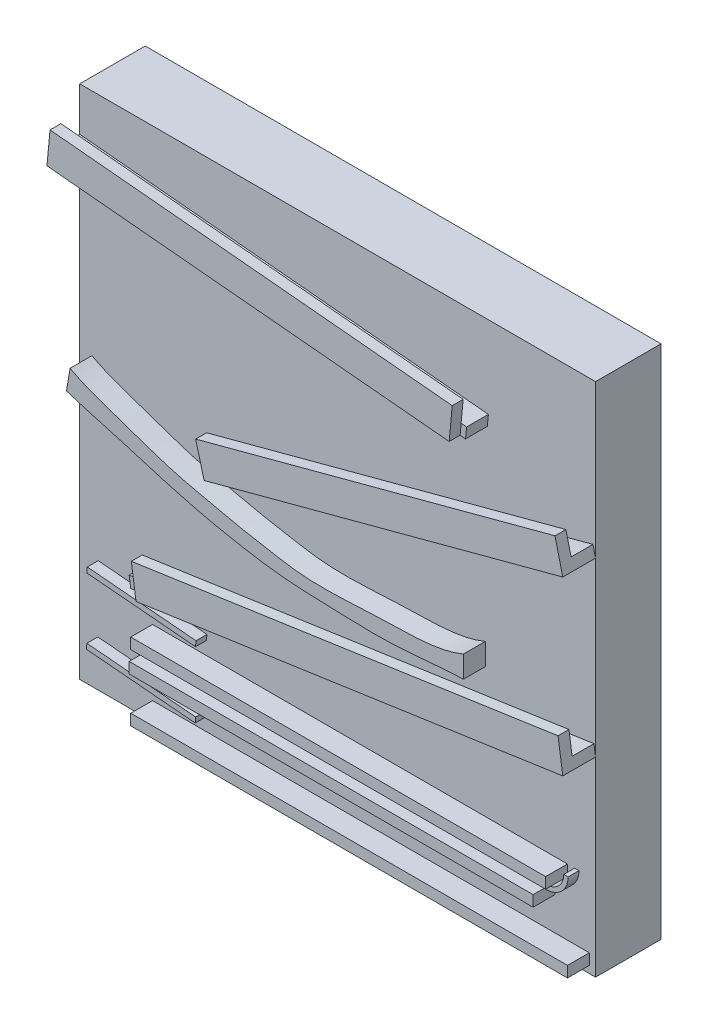
from build123d import *

# Parameters (mm, degrees)
SKETCH1_W            = 600
SKETCH1_H            = 600
BOSS_EXTRUDE1_DEPTH  = 76.2
BOSS_EXTRUDE2_DEPTH  = 25.4
BOSS_EXTRUDE3_START  = 25.4
BOSS_EXTRUDE3_DEPTH  = 12.7
BOSS_EXTRUDE4_DEPTH  = 25.4
BOSS_EXTRUDE5_START  = 25.4
BOSS_EXTRUDE5_DEPTH  = 12.7
BOSS_EXTRUDE6_DEPTH  = 25.4
SKETCH1_42_W         = 482.6
SKETCH1_42_H         = 12.7
SKETCH1_42_W_2       = 469.9
SKETCH1_42_W_3       = 508
BOSS_EXTRUDE7_DEPTH  = 25.4
BOSS_EXTRUDE8_DEPTH  = 12.7
BOSS_EXTRUDE9_START  = 25.4
BOSS_EXTRUDE9_DEPTH  = 12.7
BOSS_EXTRUDE10_DEPTH = 25.4


with BuildPart() as part:
    # Sketch1 → Boss-Extrude1 (new body)
    with BuildSketch(Plane.XY):
        with Locations((-225.240056073, 6.540000857)):
            Rectangle(SKETCH1_W, SKETCH1_H)
    extrude(amount=-BOSS_EXTRUDE1_DEPTH)

    # Sketch1_22 → Boss-Extrude2 (add)
    with BuildSketch(Plane.XY):
        Polygon((-525.240056073, 242.984461231), (-525.240056073, 255.740000857), (-49.879871206, 211.234703059), (-51.063723483, 198.590000857), align=None)
    extrude(amount=BOSS_EXTRUDE2_DEPTH)

    # Sketch1_23 → Boss-Extrude3 (add)
    with BuildSketch(Plane.XY.offset(BOSS_EXTRUDE3_START)):
        Polygon((-525.240056073, 242.984461231), (-57.386074584, 199.181926995), (-53.834517754, 237.116033602), (-521.688499243, 280.918567838), align=None)
    extrude(amount=BOSS_EXTRUDE3_DEPTH)

    # Sketch1_36 → Boss-Extrude4 (add)
    with BuildSketch(Plane.XY):
        Polygon((-342.440287545, 17.406237518), (74.759943927, 128.740000857), (71.744479474, 141.079727937), (-345.714809996, 29.676832561), align=None)
    extrude(amount=BOSS_EXTRUDE4_DEPTH)

    # Sketch1_38 → Boss-Extrude5 (add)
    with BuildSketch(Plane.XY.offset(BOSS_EXTRUDE5_START)):
        Polygon((-342.440287545, 17.406237518), (74.759943927, 128.740000857), (65.713550566, 165.759182097), (-352.263854899, 54.218022648), align=None)
    extrude(amount=BOSS_EXTRUDE5_DEPTH)

    # Sketch1_39 → Boss-Extrude6 (add)
    with BuildSketch(Plane.XY):
        with BuildLine():
            Line((-515.232510143, 14.731286418), (-511.049397451, 39.784461231))
            add(Edge.make_bspline(
                [(-511.049397451, 39.784461231), (-491.91342743, 29.210221806), (-458.77856372, 19.531721492), (-416.625986292, 3.959066392), (-383.903580076, -6.249374557), (-350.315397205, -13.252889549), (-315.502078412, -21.570378936), (-279.518469533, -27.808056985), (-243.831298859, -34.151990356), (-199.456462469, -34.752149035), (-135.713837898, -30.00036949), (-83.078004242, -31.661348956), (-53.461097288, -19.3009415)],
                knots=[0, 0, 0, 0, 0.138195141, 0.220153512, 0.28706639, 0.356885041, 0.439197272, 0.515633138, 0.590194642, 0.670343679, 0.797980141, 1, 1, 1, 1], degree=3))
            Line((-53.461097288, -19.3009415), (-53.461097288, -44.7009415))
            add(Edge.make_bspline(
                [(-515.232510143, 14.731286418), (-492.287448082, 7.361196537), (-460.683716745, -0.781157172), (-419.974441586, -13.502513213), (-388.83188488, -22.419811825), (-355.455504677, -31.276728095), (-317.590964539, -38.781286591), (-279.774049612, -45.52299243), (-241.592265326, -48.592909593), (-194.728275521, -49.903260595), (-132.907153847, -52.623676823), (-81.911313969, -45.613021801), (-53.461097288, -44.7009415)],
                knots=[0, 0, 0, 0, 0.153828341, 0.208264646, 0.272296669, 0.360672756, 0.428620212, 0.51872685, 0.605764862, 0.672841047, 0.818182432, 1, 1, 1, 1], degree=3))
        make_face()
    extrude(amount=BOSS_EXTRUDE6_DEPTH)

    # Sketch1_42 → Boss-Extrude7 (add)
    with BuildSketch(Plane.XY):
        with Locations((-199.186590665, -202.053329244)):
            Rectangle(SKETCH1_42_W, SKETCH1_42_H)
        with Locations((-207.36885806, -227.48194535)):
            Rectangle(SKETCH1_42_W_2, SKETCH1_42_H)
        with Locations((-186.486590665, -278.810327036)):
            Rectangle(SKETCH1_42_W_3, SKETCH1_42_H)
    extrude(amount=BOSS_EXTRUDE7_DEPTH)

    # Sketch1_43 → Boss-Extrude8 (add)
    with BuildSketch(Plane.XY):
        Polygon((-377.277754824, -174.137492911), (-503.794481482, -163.068713582), (-504.347920448, -169.394549915), (-377.831193791, -180.463329244), align=None)
        with BuildLine():
            Line((55.52114194, -195.703329244), (50.469758046, -195.703329244))
            ThreePointArc((50.469758046, -195.703329244), (44.509786376, -210.09197368), (30.12114194, -216.05194535))
            Line((30.12114194, -216.05194535), (30.12114194, -221.103329244))
            ThreePointArc((30.12114194, -221.103329244), (48.081654182, -213.663841486), (55.52114194, -195.703329244))
        make_face()
        Polygon((-504.198568844, -240.134266294), (-504.752007811, -246.460102627), (-378.235281153, -257.528881956), (-377.681842187, -251.203045623), align=None)
    extrude(amount=BOSS_EXTRUDE8_DEPTH)



with BuildPart() as body_2:
    # Sketch1_46 → Boss-Extrude9 (new body)
    with BuildSketch(Plane.XY.offset(BOSS_EXTRUDE9_START)):
        Polygon((74.759943927, -71.628181651), (69.260201501, -33.927215705), (-427.135850118, -106.340490986), (-421.636107692, -144.041456932), align=None)
    extrude(amount=BOSS_EXTRUDE9_DEPTH)


with BuildPart() as part_1:
    add(part.part)

    add(body_2.part)  # Boss-Extrude10 merges body 2
    # Sketch1_47 → Boss-Extrude10 (add)
    with BuildSketch(Plane.XY):
        Polygon((74.759943927, -71.628181651), (72.926696452, -59.061193002), (-442.31983814, -134.224339496), (-440.486590665, -146.791328145), align=None)
    extrude(amount=BOSS_EXTRUDE10_DEPTH)


solid = part_1.part
